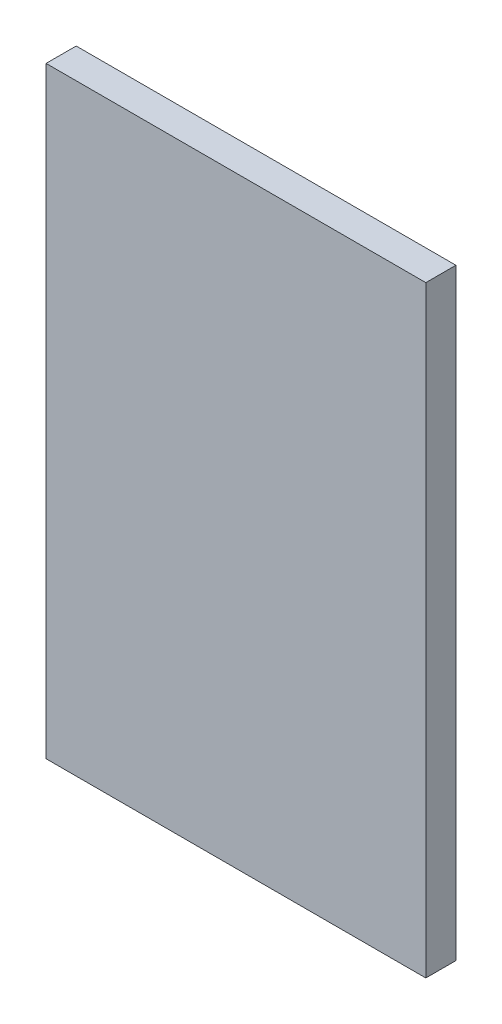
from build123d import *

# Parameters (mm, degrees)
SKETCH1_W           = 560.57
SKETCH1_H           = 889
BOSS_EXTRUDE1_DEPTH = 44.45
CUT_EXTRUDE2_DEPTH  = 381


with BuildPart() as part:
    # Sketch1 → Boss-Extrude1 (new body)
    with BuildSketch(Plane.XY):
        with Locations((280.285, -444.5)):
            Rectangle(SKETCH1_W, SKETCH1_H)
    extrude(amount=BOSS_EXTRUDE1_DEPTH)

    # Sketch2 → Cut-Extrude2 (cut, symmetric)
    with BuildSketch(Plane(origin=(0, -444.5, 0), x_dir=(1, 0, 0), z_dir=(0, 1, 0))):
        with BuildLine():
            Line((75.435663802, -10), (75.435663802, 0))
            Line((75.435663802, 0), (111.564336198, 0))
            Line((111.564336198, 0), (111.564336198, -10))
            ThreePointArc((111.564336198, -10), (93.5, -23.001673148), (75.435663802, -10))
        make_face()
        with BuildLine():
            Line((168.935663802, -10), (168.935663802, 0))
            Line((168.935663802, 0), (205.064336198, 0))
            Line((205.064336198, 0), (205.064336198, -10))
            ThreePointArc((205.064336198, -10), (187, -23.001673148), (168.935663802, -10))
        make_face()
    cut_extrude2 = extrude(amount=CUT_EXTRUDE2_DEPTH, both=True, mode=Mode.SUBTRACT)

    # Mirror1: Cut-Extrude2 across plane
    add(cut_extrude2.mirror(Plane.ZY.offset(-280.285)), mode=Mode.SUBTRACT)


solid = part.part
